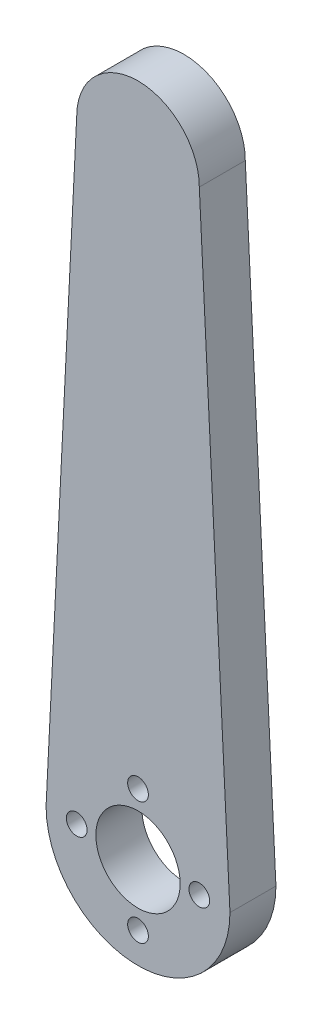
from build123d import *

# Parameters (mm, degrees)
BOSS_EXTRU_1_DEPTH           = 6
ESQUISSE2_R                  = 5.5
ESQUISSE2_R_2                = 1.35
ENL_V_MAT_EXTRU_1_DEPTH      = 1
ENL_V_MAT_EXTRU_1_DEPTH_BACK = 7


with BuildPart() as part:
    # Esquisse1 → Boss.-Extru.1 (new body)
    with BuildSketch(Plane.XY):
        with BuildLine():
            Line((12, 0), (8, 80))
            ThreePointArc((8, 80), (0, 88), (-8, 80))
            Line((-8, 80), (-12, 0))
            ThreePointArc((-12, 0), (0, -12), (12, 0))
        make_face()
    extrude(amount=BOSS_EXTRU_1_DEPTH)

    # Esquisse2 → Enlèv. mat.-Extru.1 (cut, two sides)
    with BuildSketch(Plane.XY.offset(6)) as enl_v_mat_extru_1_sk:
        Circle(ESQUISSE2_R)
        with Locations((8, 0)):
            Circle(ESQUISSE2_R_2)
        with Locations((0, -8)):
            Circle(ESQUISSE2_R_2)
        with Locations((-8, 0)):
            Circle(ESQUISSE2_R_2)
        with Locations((0, 8)):
            Circle(ESQUISSE2_R_2)
    extrude(amount=ENL_V_MAT_EXTRU_1_DEPTH, mode=Mode.SUBTRACT)
    extrude(enl_v_mat_extru_1_sk.sketch, amount=-ENL_V_MAT_EXTRU_1_DEPTH_BACK, mode=Mode.SUBTRACT)


solid = part.part
